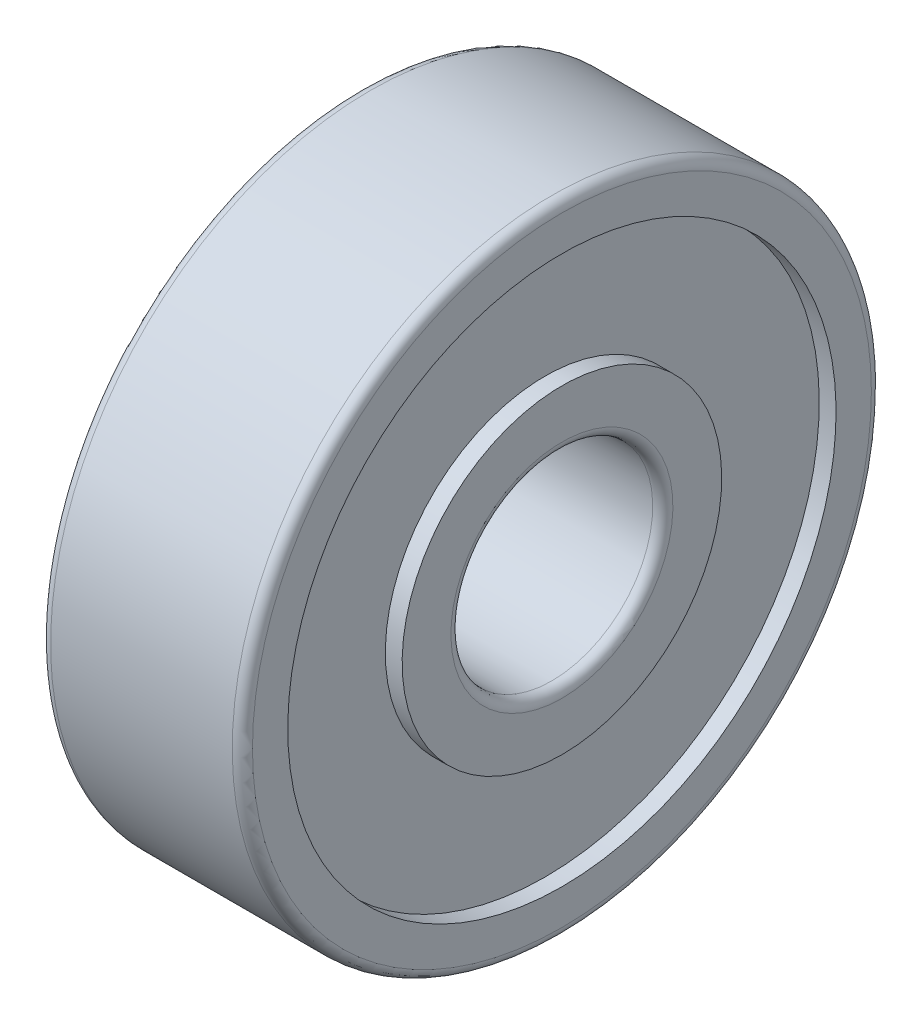
from build123d import *

# Parameters (mm, degrees)
FILLET1_R = 0.3
FILLET2_R = 0.3


with BuildPart() as part:
    # Sketch1 → Revolve1 (revolve)
    with BuildSketch(Plane.XY):
        Polygon((0, 3), (6, 3), (6, 4.75), (5.5, 4.75), (5.5, 8.15), (6, 8.15), (6, 9.5), (0, 9.5), (0, 8.15), (0.5, 8.15), (0.5, 4.75), (0, 4.75), align=None)
    revolve(axis=Axis((0, 0, 0), (1, 0, 0)))

    # Fillet1
    fillet1_edges = [part.edges().sort_by_distance(p)[0] for p in [
        (0, -9.5, 0),
        (6, -9.5, 0),
    ]]
    fillet(fillet1_edges, radius=FILLET1_R)

    # Fillet2
    fillet2_edges = [part.edges().sort_by_distance(p)[0] for p in [
        (6, -3, 0),
        (0, -3, 0),
    ]]
    fillet(fillet2_edges, radius=FILLET2_R)


solid = part.part
